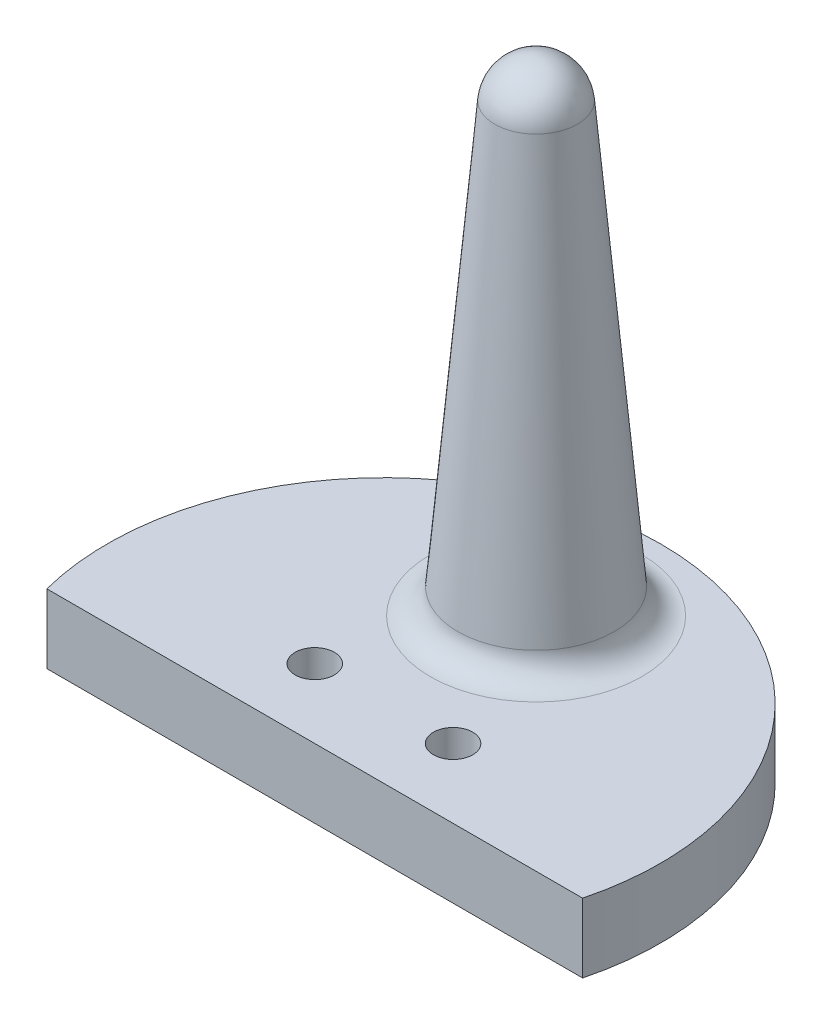
from build123d import *

# Parameters (mm, degrees)
SKETCH1_R           = 1.42
BOSS_EXTRUDE1_DEPTH = 5
FILLET1_R           = 2


with BuildPart() as part:
    # Sketch1 → Boss-Extrude1 (new body)
    with BuildSketch(Plane(origin=(0, 0, 0), x_dir=(1, 0, 0), z_dir=(0, 1, 0))):
        with BuildLine():
            Line((-19.364916731, -5), (19.364916731, -5))
            ThreePointArc((19.364916731, -5), (0, 20), (-19.364916731, -5))
        make_face()
        with Locations((-5, 0)):
            Circle(SKETCH1_R, mode=Mode.SUBTRACT)
        with Locations((5, 0)):
            Circle(SKETCH1_R, mode=Mode.SUBTRACT)
    extrude(amount=BOSS_EXTRUDE1_DEPTH)

    # Sketch2 → Revolve1 (revolve)
    with BuildSketch(Plane.XY.offset(-11)):
        with BuildLine():
            Line((0, 5), (0, 40))
            ThreePointArc((0, 40), (-2.026770623, 39.21183201), (-2.988584094, 37.261467228))
            Line((-2.988584094, 37.261467228), (-5.811096745, 5))
            Line((-5.811096745, 5), (0, 5))
        make_face()
    revolve(axis=Axis((0, 5, -11), (0, 1, 0)))

    # Fillet1
    fillet1_edges = [part.edges().sort_by_distance(p)[0] for p in [
        (5.811096745, 5, -11),
    ]]
    fillet(fillet1_edges, radius=FILLET1_R)


solid = part.part
